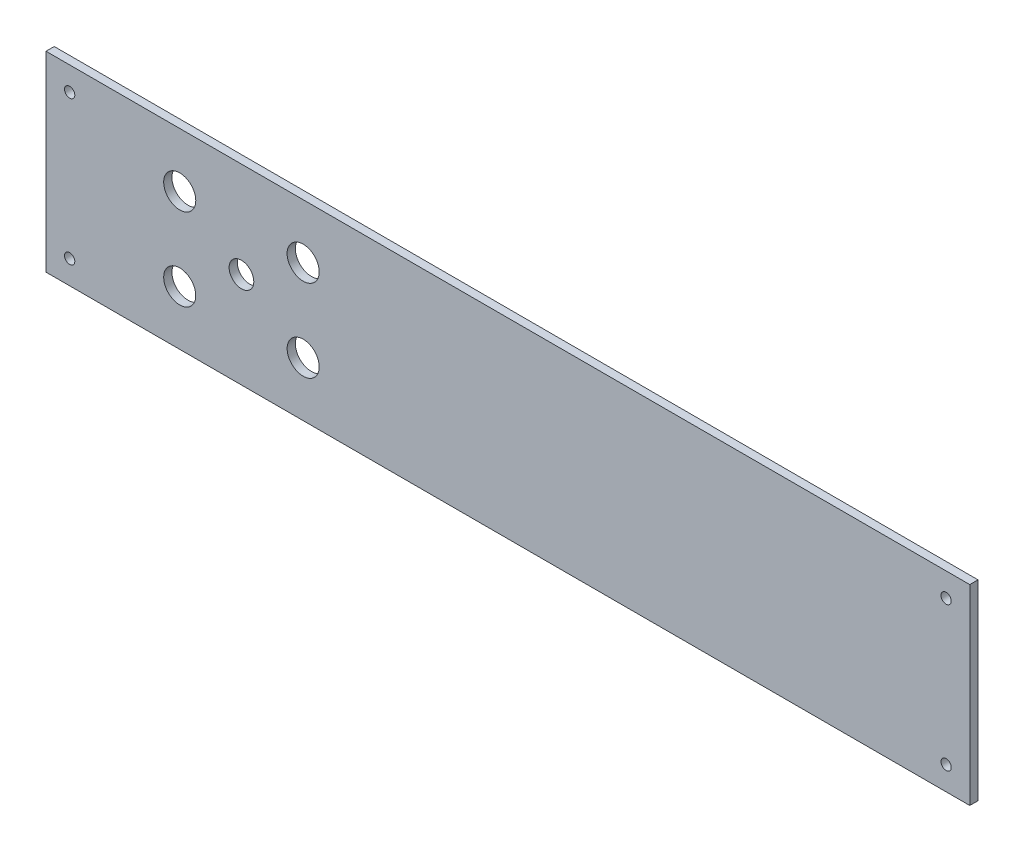
from build123d import *

# Parameters (mm, degrees)
SCHIZZO1_W                   = 449
SCHIZZO1_H                   = 93
SCHIZZO1_R                   = 7.8
SCHIZZO1_R_2                 = 2.5
SCHIZZO1_R_3                 = 6
ESTRUSIONE_ESTRUSIONE1_DEPTH = 4


with BuildPart() as part:
    # Schizzo1 → Estrusione-Estrusione1 (new body)
    with BuildSketch(Plane.XY):
        with Locations((-224.5, 46.5)):
            Rectangle(SCHIZZO1_W, SCHIZZO1_H)
        with Locations((-384, 26.5)):
            Circle(SCHIZZO1_R, mode=Mode.SUBTRACT)
        with Locations((-437.5, 81.5)):
            Circle(SCHIZZO1_R_2, mode=Mode.SUBTRACT)
        with Locations((-11.5, 81.5)):
            Circle(SCHIZZO1_R_2, mode=Mode.SUBTRACT)
        with Locations((-11.5, 11.5)):
            Circle(SCHIZZO1_R_2, mode=Mode.SUBTRACT)
        with Locations((-437.5, 11.5)):
            Circle(SCHIZZO1_R_2, mode=Mode.SUBTRACT)
        with Locations((-324, 26.5)):
            Circle(SCHIZZO1_R, mode=Mode.SUBTRACT)
        with Locations((-324, 66.5)):
            Circle(SCHIZZO1_R, mode=Mode.SUBTRACT)
        with Locations((-384, 66.5)):
            Circle(SCHIZZO1_R, mode=Mode.SUBTRACT)
        with Locations((-354, 46.5)):
            Circle(SCHIZZO1_R_3, mode=Mode.SUBTRACT)
    extrude(amount=ESTRUSIONE_ESTRUSIONE1_DEPTH)


solid = part.part
